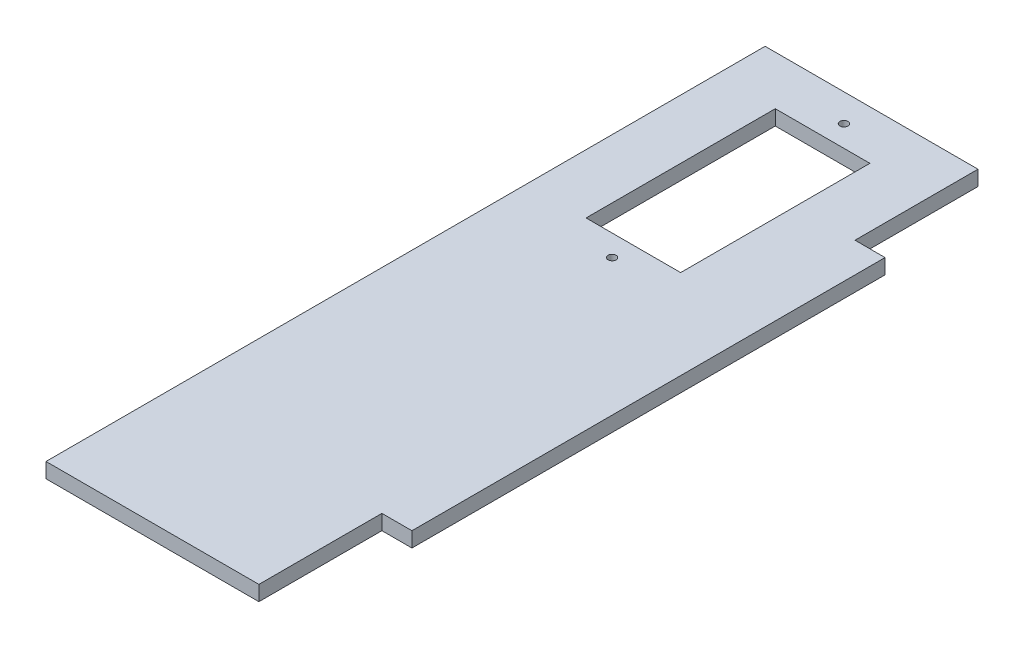
from build123d import *

# Parameters (mm, degrees)
BOSS_EXTRUDE1_DEPTH    = 3.175
SKETCH2_W              = 20
SKETCH2_H              = 40
CUT_EXTRUDE1_DEPTH     = 130.299664056
M1_6_CLEARANCE_HOLE1_D = 1.7


with BuildPart() as part:
    # Sketch1 → Boss-Extrude1 (new body)
    with BuildSketch(Plane(origin=(0, 0, 0), x_dir=(1, 0, 0), z_dir=(0, 1, 0))):
        Polygon((-22.5, 0), (-22.5, 26), (22.5, 26), (22.5, 0), (28.85, 0), (28.85, -100), (22.5, -100), (22.5, -126), (-22.5, -126), (-22.5, -100), align=None)
    extrude(amount=BOSS_EXTRUDE1_DEPTH)

    # Sketch2 → Cut-Extrude1 (cut, through all)
    with BuildSketch(Plane(origin=(0, 3.175, 0), x_dir=(1, 0, 0), z_dir=(0, 1, 0))):
        with Locations((0, -4.35)):
            Rectangle(SKETCH2_W, SKETCH2_H)
    extrude(amount=-CUT_EXTRUDE1_DEPTH, mode=Mode.SUBTRACT)

    # M1.6 Clearance Hole1 (through all)
    with Locations(Plane(origin=(0, 3.175, 0), x_dir=(1, 0, 0), z_dir=(0, 1, 0))):
        with Locations((0, -28.85), (0, 20.15)):
            Hole(M1_6_CLEARANCE_HOLE1_D / 2)


solid = part.part
